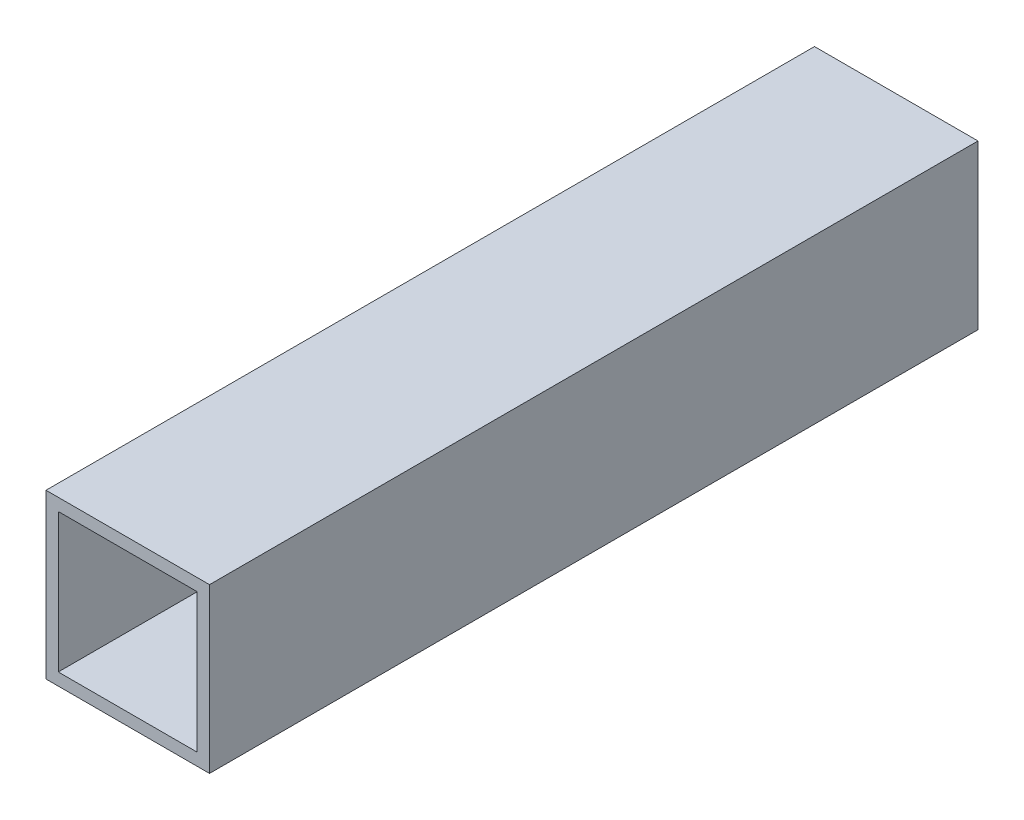
from build123d import *

# Parameters (mm, degrees)
SKETCH1_W           = 20
SKETCH1_H           = 20
SKETCH1_W_2         = 17
SKETCH1_H_2         = 17
BOSS_EXTRUDE1_DEPTH = 94


with BuildPart() as part:
    # Sketch1 → Boss-Extrude1 (new body)
    with BuildSketch(Plane.XY):
        with Locations((1.834042947, -1.477276695)):
            Rectangle(SKETCH1_W, SKETCH1_H)
        with Locations((1.834042947, -1.477276695)):
            Rectangle(SKETCH1_W_2, SKETCH1_H_2, mode=Mode.SUBTRACT)
    extrude(amount=BOSS_EXTRUDE1_DEPTH)


solid = part.part
